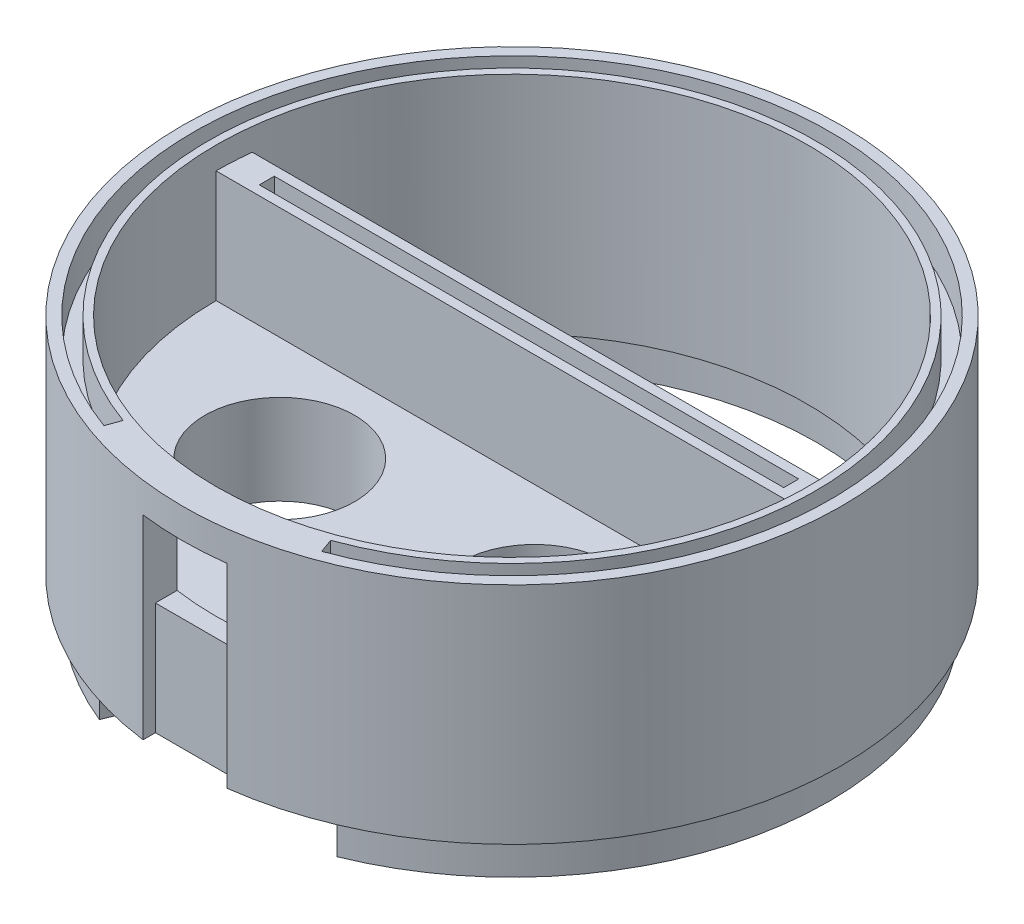
from build123d import *

# Parameters (mm, degrees)
SKETCH1_R           = 44
BOSS_EXTRUDE1_DEPTH = 180
SKETCH7_R           = 39.5
CUT_EXTRUDE1_DEPTH  = 115
SKETCH8_R           = 35
CUT_EXTRUDE2_DEPTH  = 18
SKETCH12_W          = 11.2
SKETCH12_H          = 156.702496638
CUT_EXTRUDE5_DEPTH  = 13.6
SKETCH14_W          = 11.2
SKETCH14_H          = 8.676367157
CUT_EXTRUDE6_DEPTH  = 18
SKETCH18_R          = 39.5
CUT_EXTRUDE8_DEPTH  = 12
CUT_EXTRUDE4_DEPTH  = 21
CUT_EXTRUDE9_DEPTH  = 28
SKETCH21_R          = 44
CUT_EXTRUDE10_DEPTH = 10
CUT_EXTRUDE11_DEPTH = 50
SKETCH24_R          = 10
CUT_EXTRUDE12_DEPTH = 16
SKETCH26_W          = 11.2
SKETCH26_H          = 11
CUT_EXTRUDE13_DEPTH = 14
SKETCH27_R          = 39
CUT_EXTRUDE14_DEPTH = 30
SKETCH28_R          = 47
SKETCH28_R_2        = 42
BOSS_EXTRUDE2_DEPTH = 20
CUT_EXTRUDE15_DEPTH = 40
SKETCH30_R          = 47
CUT_EXTRUDE16_DEPTH = 20
SKETCH33_R          = 44
CUT_EXTRUDE17_DEPTH = 137
BOSS_EXTRUDE4_DEPTH = 5
SKETCH35_W          = 70
SKETCH35_H          = 2
CUT_EXTRUDE18_DEPTH = 5
SKETCH37_R          = 44
CUT_EXTRUDE19_DEPTH = 9
CUT_EXTRUDE20_DEPTH = 5


with BuildPart() as part:
    # Sketch1 → Boss-Extrude1 (new body)
    with BuildSketch(Plane(origin=(0, 0, 0), x_dir=(1, 0, 0), z_dir=(0, 1, 0))):
        Circle(SKETCH1_R)
    extrude(amount=BOSS_EXTRUDE1_DEPTH)

    # Sketch7 → Cut-Extrude1 (cut)
    with BuildSketch(Plane(origin=(0, 25, 0), x_dir=(1, 0, 0), z_dir=(0, 1, 0))):
        Circle(SKETCH7_R)
    extrude(amount=CUT_EXTRUDE1_DEPTH, mode=Mode.SUBTRACT)

    # Sketch8 → Cut-Extrude2 (cut)
    with BuildSketch(Plane(origin=(0, 41, 0), x_dir=(1, 0, 0), z_dir=(0, 1, 0))):
        Circle(SKETCH8_R)
    extrude(amount=-CUT_EXTRUDE2_DEPTH, mode=Mode.SUBTRACT)

    # Sketch12 → Cut-Extrude5 (cut)
    with BuildSketch(Plane.XY.offset(42)):
        with Locations((0, 88.648751681)):
            Rectangle(SKETCH12_W, SKETCH12_H)
    extrude(amount=CUT_EXTRUDE5_DEPTH, mode=Mode.SUBTRACT)

    # Sketch14 → Cut-Extrude6 (cut)
    with BuildSketch(Plane.XY.offset(42)):
        with Locations((0, 14.635686941)):
            Rectangle(SKETCH14_W, SKETCH14_H)
    extrude(amount=-CUT_EXTRUDE6_DEPTH, mode=Mode.SUBTRACT)

    # Sketch18 → Cut-Extrude8 (cut)
    with BuildSketch(Plane(origin=(0, 180, 0), x_dir=(1, 0, 0), z_dir=(0, 1, 0))):
        Circle(SKETCH18_R)
    extrude(amount=-CUT_EXTRUDE8_DEPTH, mode=Mode.SUBTRACT)

    # Sketch10 → Cut-Extrude4 (cut, symmetric)
    with BuildSketch(Plane(origin=(0, 174, 0), x_dir=(1, 0, 0), z_dir=(0, 1, 0))):
        with BuildLine():
            Line((-39.5, 0), (39.5, 0))
            ThreePointArc((39.5, 0), (0, -39.5), (-39.5, 0))
        make_face()
    extrude(amount=CUT_EXTRUDE4_DEPTH, both=True, mode=Mode.SUBTRACT)

    # Sketch20 → Cut-Extrude9 (cut)
    with BuildSketch(Plane(origin=(0, 168, 0), x_dir=(1, 0, 0), z_dir=(0, 1, 0))):
        with BuildLine():
            Line((9, 26), (-15, 26))
            ThreePointArc((-15, 26), (-18.535533906, 24.535533906), (-20, 21))
            Line((-20, 21), (-20, 10))
            ThreePointArc((-20, 10), (-18.535533906, 6.464466094), (-15, 5))
            Line((-15, 5), (9, 5))
            ThreePointArc((9, 5), (12.535533906, 6.464466094), (14, 10))
            Line((14, 10), (14, 21))
            ThreePointArc((14, 21), (12.535533906, 24.535533906), (9, 26))
        make_face()
    extrude(amount=-CUT_EXTRUDE9_DEPTH, mode=Mode.SUBTRACT)

    # Sketch21 → Cut-Extrude10 (cut)
    with BuildSketch(Plane(origin=(0, 5, 0), x_dir=(1, 0, 0), z_dir=(0, 1, 0))):
        Circle(SKETCH21_R)
    extrude(amount=-CUT_EXTRUDE10_DEPTH, mode=Mode.SUBTRACT)

    # Sketch23 → Cut-Extrude11 (cut)
    with BuildSketch(Plane(origin=(0, 168, 0), x_dir=(1, 0, 0), z_dir=(0, 1, 0))):
        with BuildLine():
            Line((-34.700571143, 4.568409172), (34.700571143, 4.568409172))
            ThreePointArc((34.700571143, 4.568409172), (0, 35), (-34.700571143, 4.568409172))
        make_face()
    extrude(amount=-CUT_EXTRUDE11_DEPTH, mode=Mode.SUBTRACT)

    # Sketch24 → Cut-Extrude12 (cut)
    with BuildSketch(Plane(origin=(0, 153, 0), x_dir=(1, 0, 0), z_dir=(0, 1, 0))):
        with Locations((-17, -14)):
            Circle(SKETCH24_R)
        with Locations((17, -14)):
            Circle(SKETCH24_R)
    extrude(amount=-CUT_EXTRUDE12_DEPTH, mode=Mode.SUBTRACT)

    # Sketch26 → Cut-Extrude13 (cut)
    with BuildSketch(Plane.XY.offset(42)):
        with Locations((0, 161.5)):
            Rectangle(SKETCH26_W, SKETCH26_H)
    extrude(amount=-CUT_EXTRUDE13_DEPTH, mode=Mode.SUBTRACT)

    # Sketch27 → Cut-Extrude14 (cut)
    with BuildSketch(Plane.XZ.offset(-5)):
        Circle(SKETCH27_R)
    extrude(amount=-CUT_EXTRUDE14_DEPTH, mode=Mode.SUBTRACT)

    # Sketch28 → Boss-Extrude2 (add)
    with BuildSketch(Plane.XZ.offset(-5)):
        Circle(SKETCH28_R)
        Circle(SKETCH28_R_2, mode=Mode.SUBTRACT)
    extrude(amount=BOSS_EXTRUDE2_DEPTH)

    # Sketch29 → Cut-Extrude15 (cut)
    with BuildSketch(Plane(origin=(0, 168, 0), x_dir=(1, 0, 0), z_dir=(0, 1, 0))):
        with BuildLine():
            Line((-39.234928796, 4.568409172), (-34.700571143, 4.568409172))
            ThreePointArc((-34.700571143, 4.568409172), (0, 35), (34.700571143, 4.568409172))
            Line((34.700571143, 4.568409172), (39.234928796, 4.568409172))
            ThreePointArc((39.234928796, 4.568409172), (0, 39.5), (-39.234928796, 4.568409172))
        make_face()
    extrude(amount=-CUT_EXTRUDE15_DEPTH, mode=Mode.SUBTRACT)

    # Sketch30 → Cut-Extrude16 (cut)
    with BuildSketch(Plane.XZ.offset(15)):
        Circle(SKETCH30_R)
    extrude(amount=-CUT_EXTRUDE16_DEPTH, mode=Mode.SUBTRACT)

    # Sketch33 → Cut-Extrude17 (cut, through all)
    with BuildSketch(Plane(origin=(0, 141, 0), x_dir=(1, 0, 0), z_dir=(0, 1, 0))):
        Circle(SKETCH33_R)
    extrude(amount=-CUT_EXTRUDE17_DEPTH, mode=Mode.SUBTRACT)

    # Sketch34 → Boss-Extrude4 (add)
    with BuildSketch(Plane.XZ.offset(-141)):
        with BuildLine():
            Line((15.246488352, 37.736382881), (15.845858901, 39.219877048))
            ThreePointArc((15.845858901, 39.219877048), (0, -42.3), (-15.845858901, 39.219877048))
            Line((-15.845858901, 39.219877048), (-15.246488352, 37.736382881))
            ThreePointArc((-15.246488352, 37.736382881), (0, -40.7), (15.246488352, 37.736382881))
        make_face()
    extrude(amount=BOSS_EXTRUDE4_DEPTH)

    # Sketch35 → Cut-Extrude18 (cut)
    with BuildSketch(Plane(origin=(0, 168, 0), x_dir=(1, 0, 0), z_dir=(0, 1, 0))):
        with Locations((0, 2.268409172)):
            Rectangle(SKETCH35_W, SKETCH35_H)
    extrude(amount=-CUT_EXTRUDE18_DEPTH, mode=Mode.SUBTRACT)

    # Sketch37 → Cut-Extrude19 (cut)
    with BuildSketch(Plane(origin=(0, 180, 0), x_dir=(1, 0, 0), z_dir=(0, 1, 0))):
        Circle(SKETCH37_R)
    extrude(amount=-CUT_EXTRUDE19_DEPTH, mode=Mode.SUBTRACT)

    # Sketch38 → Cut-Extrude20 (cut)
    with BuildSketch(Plane(origin=(0, 171, 0), x_dir=(1, 0, 0), z_dir=(0, 1, 0))):
        with BuildLine():
            Line((-14.535856091, -39.936936383), (-13.851815805, -38.057551142))
            ThreePointArc((-13.851815805, -38.057551142), (0, 40.5), (13.851815805, -38.057551142))
            Line((13.851815805, -38.057551142), (14.535856091, -39.936936383))
            ThreePointArc((14.535856091, -39.936936383), (0, 42.5), (-14.535856091, -39.936936383))
        make_face()
    extrude(amount=-CUT_EXTRUDE20_DEPTH, mode=Mode.SUBTRACT)


solid = part.part
